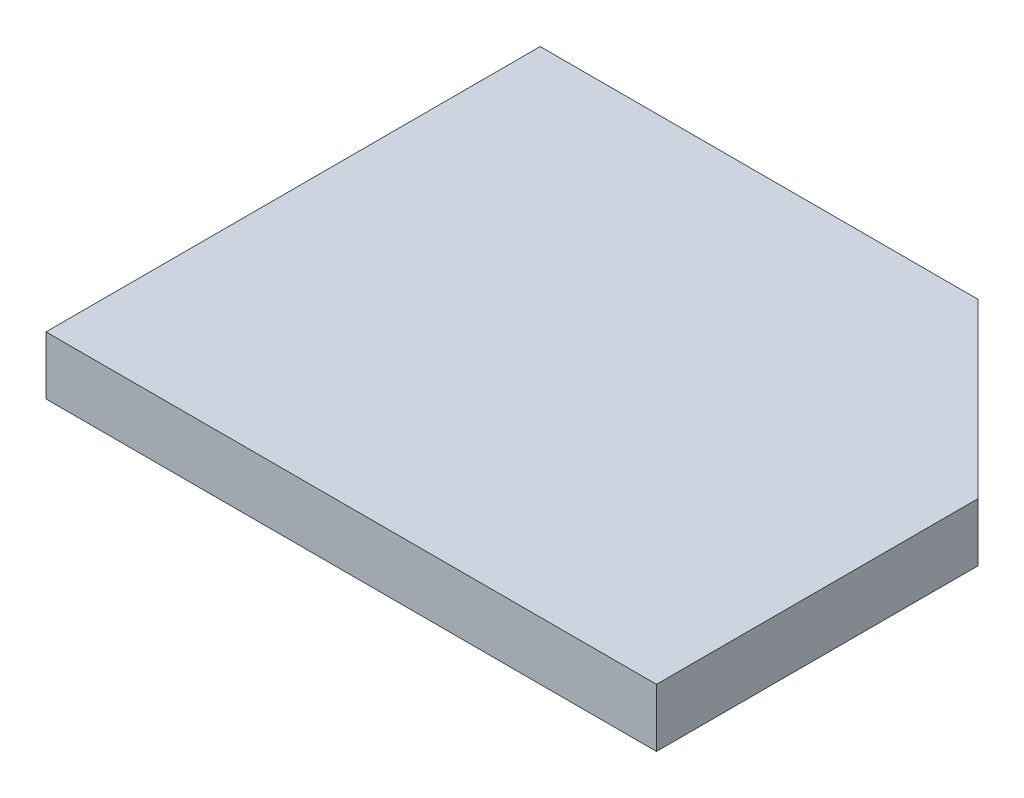
from build123d import *

# Parameters (mm, degrees)
BOSS_EXTRUDE1_DEPTH = 10


with BuildPart() as part:
    # Sketch1 → Boss-Extrude1 (new body)
    with BuildSketch(Plane(origin=(0, 0, 0), x_dir=(1, 0, 0), z_dir=(0, 1, 0))):
        Polygon((-41.160131748, 19.796063365), (-41.160131748, -65.203936635), (63.839868252, -65.203936635), (63.839868252, -9.902421445), (34.141383442, 19.796063365), align=None)
    extrude(amount=BOSS_EXTRUDE1_DEPTH)


solid = part.part
